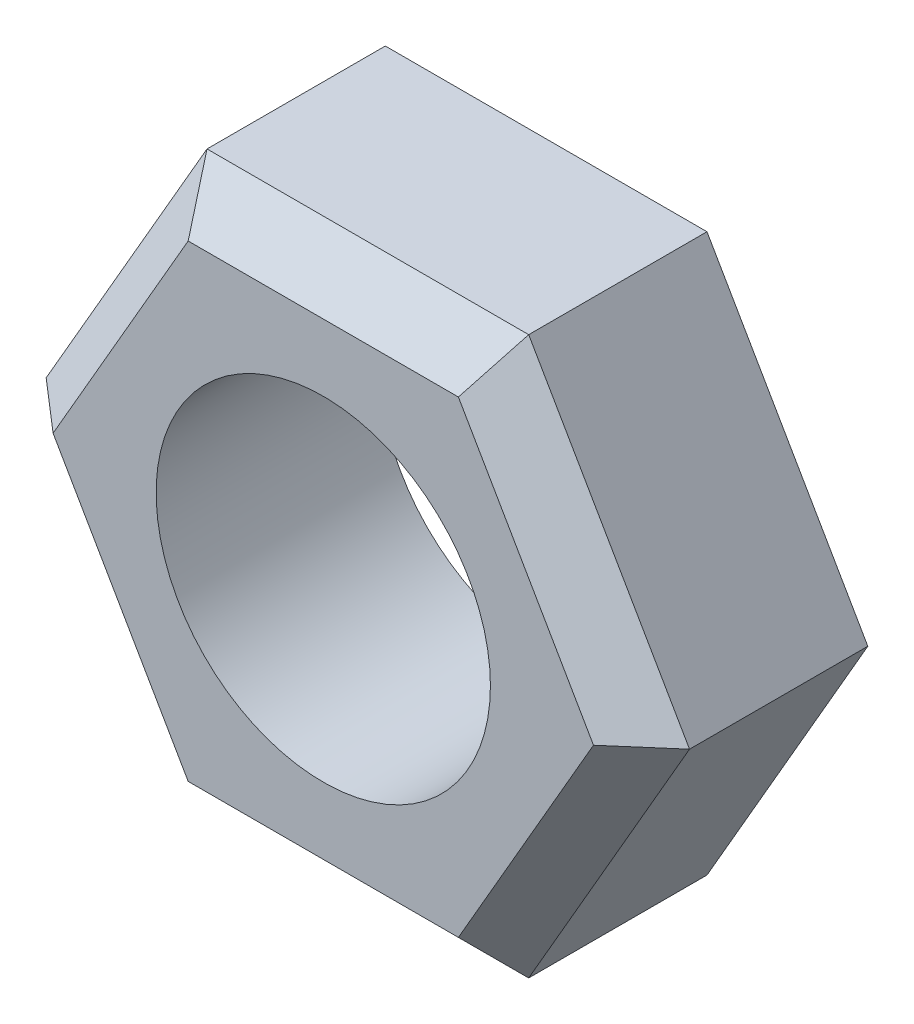
from build123d import *

# Parameters (mm, degrees)
SKETCH1_R           = 7.5
BOSS_EXTRUDE1_DEPTH = 10
CHAMFER1_SIZE       = 2


with BuildPart() as part:
    # Sketch1 → Boss-Extrude1 (new body)
    with BuildSketch(Plane.XY):
        Polygon((7.216878365, -12.5), (14.43375673, 0), (7.216878365, 12.5), (-7.216878365, 12.5), (-14.43375673, 0), (-7.216878365, -12.5), align=None)
        Circle(SKETCH1_R, mode=Mode.SUBTRACT)
    extrude(amount=BOSS_EXTRUDE1_DEPTH)

    # Chamfer1
    chamfer1_edges = [part.edges().sort_by_distance(p)[0] for p in [
        (10.825317547, 6.25, 10),
        (0, 12.5, 10),
        (-10.825317547, 6.25, 10),
        (-10.825317547, -6.25, 10),
        (0, -12.5, 10),
        (10.825317547, -6.25, 10),
    ]]
    chamfer(chamfer1_edges, length=CHAMFER1_SIZE)


solid = part.part
